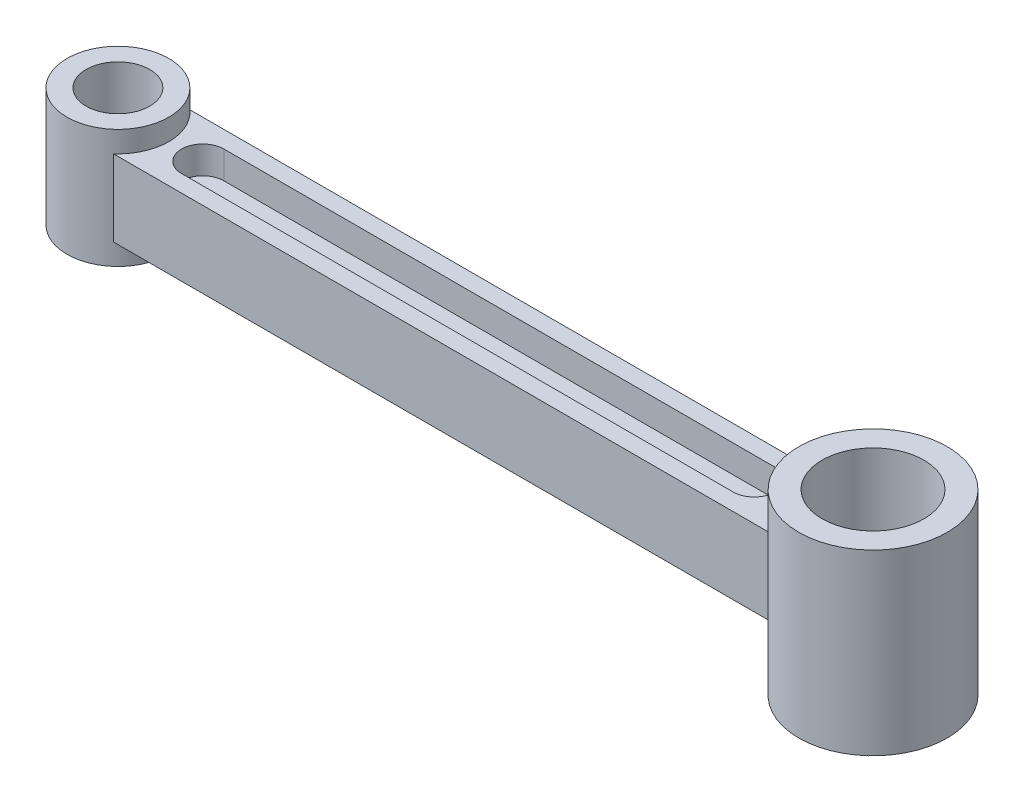
from build123d import *

# Parameters (mm, degrees)
SKETCH1_R           = 12
SKETCH1_R_2         = 7.5
BOSS_EXTRUDE1_DEPTH = 14
SKETCH6_R           = 17.5
SKETCH6_R_2         = 12
BOSS_EXTRUDE4_DEPTH = 21
BOSS_EXTRUDE5_DEPTH = 9
CUT_EXTRUDE4_DEPTH  = 6.5


with BuildPart() as part:
    # Sketch1 → Boss-Extrude1 (new body, symmetric)
    with BuildSketch(Plane(origin=(0, 0, 0), x_dir=(1, 0, 0), z_dir=(0, 1, 0))):
        Circle(SKETCH1_R)
        Circle(SKETCH1_R_2, mode=Mode.SUBTRACT)
    extrude(amount=BOSS_EXTRUDE1_DEPTH, both=True)



with BuildPart() as body_2:
    # Sketch6 → Boss-Extrude4 (new body, symmetric)
    with BuildSketch(Plane(origin=(0, 0, 0), x_dir=(1, 0, 0), z_dir=(0, 1, 0))):
        with Locations((178, 0)):
            Circle(SKETCH6_R)
        with Locations((178, 0)):
            Circle(SKETCH6_R_2, mode=Mode.SUBTRACT)
    extrude(amount=BOSS_EXTRUDE4_DEPTH, both=True)


with BuildPart() as part_1:
    add(part.part)

    add(body_2.part)  # Boss-Extrude5 merges body 2
    # Sketch14 → Boss-Extrude5 (add, symmetric)
    with BuildSketch(Plane(origin=(0, 0, 0), x_dir=(1, 0, 0), z_dir=(0, 1, 0))):
        with BuildLine():
            Line((7.937253933, -9), (162.99166898, -9))
            ThreePointArc((162.99166898, -9), (160.5, 0), (162.99166898, 9))
            Line((162.99166898, 9), (7.937253933, 9))
            ThreePointArc((7.937253933, 9), (12, 0), (7.937253933, -9))
        make_face()
    extrude(amount=BOSS_EXTRUDE5_DEPTH, both=True)

    # Sketch16 → Cut-Extrude4 (cut)
    with BuildSketch(Plane(origin=(0, 9, 0), x_dir=(1, 0, 0), z_dir=(0, 1, 0))):
        with BuildLine():
            Line((20, 5), (150, 5))
            ThreePointArc((150, 5), (155, 0), (150, -5))
            Line((150, -5), (20, -5))
            ThreePointArc((20, -5), (15, 0), (20, 5))
        make_face()
    cut_extrude4 = extrude(amount=-CUT_EXTRUDE4_DEPTH, mode=Mode.SUBTRACT)

    # Mirror1: Cut-Extrude4 across plane
    add(cut_extrude4.mirror(Plane.ZX), mode=Mode.SUBTRACT)


solid = part_1.part
